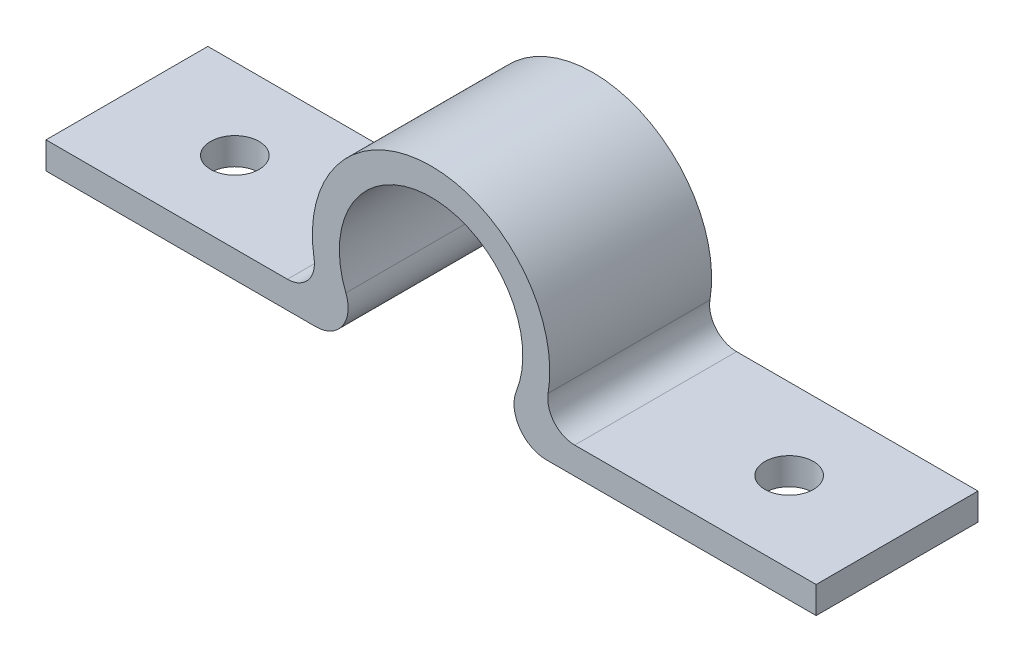
from build123d import *

# Parameters (mm, degrees)
BOSS_EXTRUDE1_DEPTH  = 30
FILLET3_R            = 5
M8_CLEARANCE_HOLE2_D = 9


with BuildPart() as part:
    # Sketch1 → Boss-Extrude1 (new body)
    with BuildSketch(Plane.XY):
        with BuildLine():
            Line((0, 5), (0, 0))
            Line((0, 0), (50, 0))
            ThreePointArc((50, 0), (54.964763693, 2.630857457), (55.575665525, 8.216292841))
            ThreePointArc((55.575665525, 8.216292841), (71.373384511, 31.495789225), (87.171103497, 8.216292841))
            ThreePointArc((87.171103497, 8.216292841), (87.782005329, 2.630857457), (92.746769021, 0))
            Line((92.746769021, 0), (142.746769021, 0))
            Line((142.746769021, 0), (142.746769021, 5))
            Line((142.746769021, 5), (91.218534724, 5))
            ThreePointArc((91.218534724, 5), (71.373384511, 36.495789225), (51.528234297, 5))
            Line((51.528234297, 5), (5, 5))
            Line((5, 5), (0, 5))
        make_face()
    extrude(amount=BOSS_EXTRUDE1_DEPTH)

    # Fillet3
    fillet3_edges = [part.edges().sort_by_distance(p)[0] for p in [
        (51.528234297, 5, 15),
        (91.218534724, 5, 15),
    ]]
    fillet(fillet3_edges, radius=FILLET3_R)

    # M8 Clearance Hole2 (through all)
    with Locations(Plane(origin=(0, 5, 0), x_dir=(1, 0, 0), z_dir=(0, 1, 0))):
        with Locations((20, -15), (122.746769021, -15)):
            Hole(M8_CLEARANCE_HOLE2_D / 2)


solid = part.part
